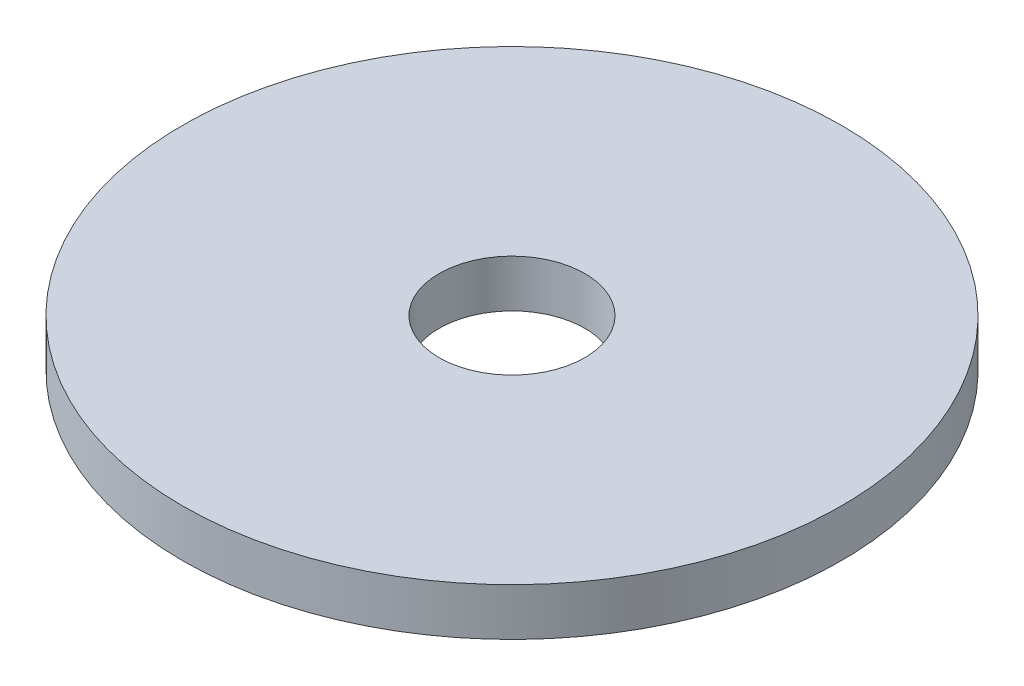
from build123d import *

# Parameters (mm, degrees)
SKETCH2_R          = 11.1125
SKETCH2_R_2        = 2.45745
BASE_EXTRUDE_DEPTH = 1.6002


with BuildPart() as part:
    # Sketch2 → Base-Extrude (new body)
    with BuildSketch(Plane(origin=(0, 0, 0), x_dir=(1, 0, 0), z_dir=(0, 1, 0))):
        Circle(SKETCH2_R)
        Circle(SKETCH2_R_2, mode=Mode.SUBTRACT)
    extrude(amount=BASE_EXTRUDE_DEPTH)


solid = part.part
